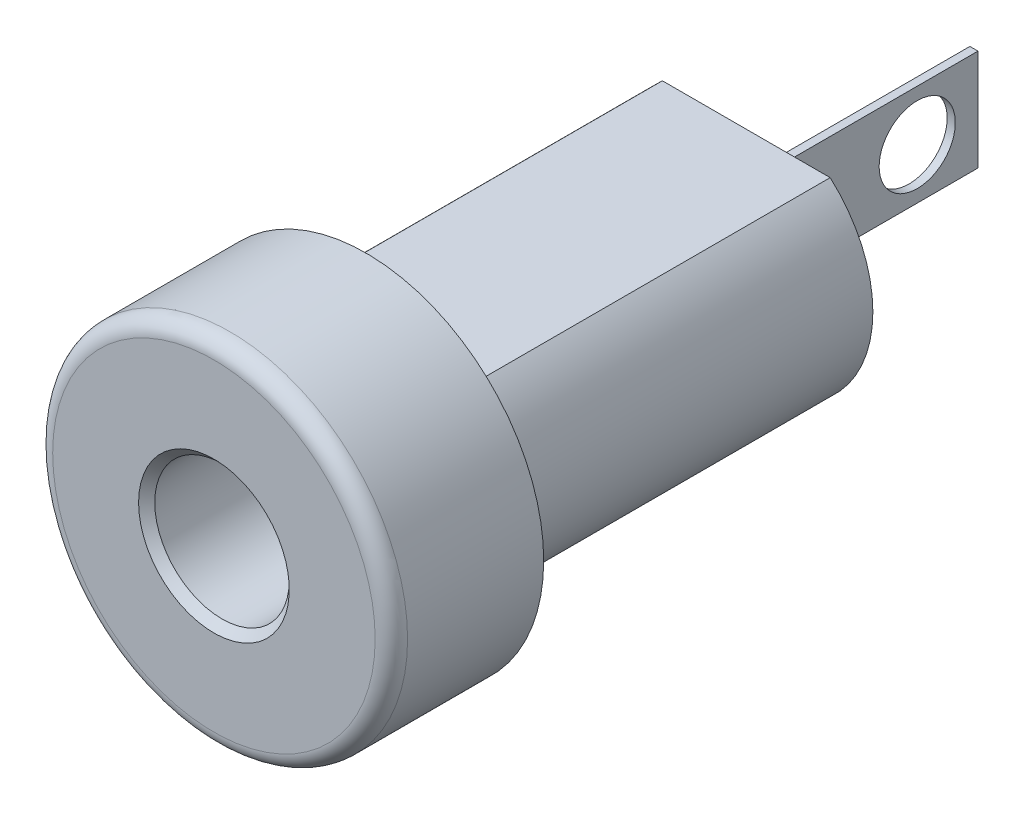
from build123d import *

# Parameters (mm, degrees)
FILLET1_R           = 0.508
SKETCH2_OUTSIDE_W   = 17.714
SKETCH2_OUTSIDE_H   = 17.714
SKETCH2_OUTSIDE_W_2 = 9.40445076
SKETCH2_OUTSIDE_H_2 = 5.9436
CUT_EXTRUDE1_DEPTH  = 11.9126
SKETCH3_W           = 0.254
SKETCH3_H           = 3.175
BOSS_EXTRUDE1_DEPTH = 7.1374
SKETCH4_R           = 1.1938
CUT_EXTRUDE2_DEPTH  = 7.1374
CUT_EXTRUDE3_DEPTH  = 7.1374
SKETCH7_R           = 2.1082
CUT_EXTRUDE4_DEPTH  = 15.875
CHAMFER2_SIZE       = 0.254


with BuildPart() as part:
    # Sketch1 → Revolve1 (revolve)
    with BuildSketch(Plane(origin=(0, 0, 0), x_dir=(0, 0, -1), z_dir=(1, 0, 0)), mode=Mode.PRIVATE) as revolve1_sk:
        Polygon((0, 0), (0, 5.5626), (4.7752, 5.5626), (4.7752, 3.96875), (16.6878, 3.96875), (16.6878, 0), align=None)
    revolve(revolve1_sk.sketch.rotate(Axis((0, 0, 0), (0, 0, -1)), 90), axis=Axis((0, 0, 0), (0, 0, -1)))  # turned: the seam where the file's is

    # Fillet1
    fillet1_edges = [part.edges().sort_by_distance(p)[0] for p in [
        (-5.5626, 0, 0),
    ]]
    fillet(fillet1_edges, radius=FILLET1_R)

    # Sketch2 outside → Cut-Extrude1 (cut)
    with BuildSketch(Plane(origin=(0, 0, -16.6878), x_dir=(-1, 0, 0), z_dir=(0, 0, -1))):
        Rectangle(SKETCH2_OUTSIDE_W, SKETCH2_OUTSIDE_H)
        Rectangle(SKETCH2_OUTSIDE_W_2, SKETCH2_OUTSIDE_H_2, mode=Mode.SUBTRACT)
    extrude(amount=-CUT_EXTRUDE1_DEPTH, mode=Mode.SUBTRACT)

    # Sketch3 → Boss-Extrude1 (add)
    with BuildSketch(Plane(origin=(0, 0, -16.6878), x_dir=(-1, 0, 0), z_dir=(0, 0, -1))):
        Rectangle(SKETCH3_W, SKETCH3_H)
    extrude(amount=BOSS_EXTRUDE1_DEPTH)

    # Sketch4 → Cut-Extrude2 (cut)
    with BuildSketch(Plane.ZY.offset(0.127)):
        with Locations((-21.9202, 0)):
            Circle(SKETCH4_R)
    extrude(amount=-CUT_EXTRUDE2_DEPTH, mode=Mode.SUBTRACT)

    # Sketch5 → Cut-Extrude3 (cut)
    with BuildSketch(Plane.ZY.offset(0.127)):
        Polygon((-16.6878, 1.5875), (-16.6878, 1.2065), (-17.3228, 1.5875), align=None)
        Polygon((-16.6878, -1.2065), (-17.3228, -1.5875), (-16.6878, -1.5875), align=None)
    extrude(amount=-CUT_EXTRUDE3_DEPTH, mode=Mode.SUBTRACT)

    # Sketch7 → Cut-Extrude4 (cut)
    with BuildSketch(Plane.XY):
        Circle(SKETCH7_R)
    extrude(amount=-CUT_EXTRUDE4_DEPTH, mode=Mode.SUBTRACT)

    # Chamfer2
    chamfer2_edges = [part.edges().sort_by_distance(p)[0] for p in [
        (-2.1082, 0, 0),
    ]]
    chamfer(chamfer2_edges, length=CHAMFER2_SIZE)


solid = part.part
